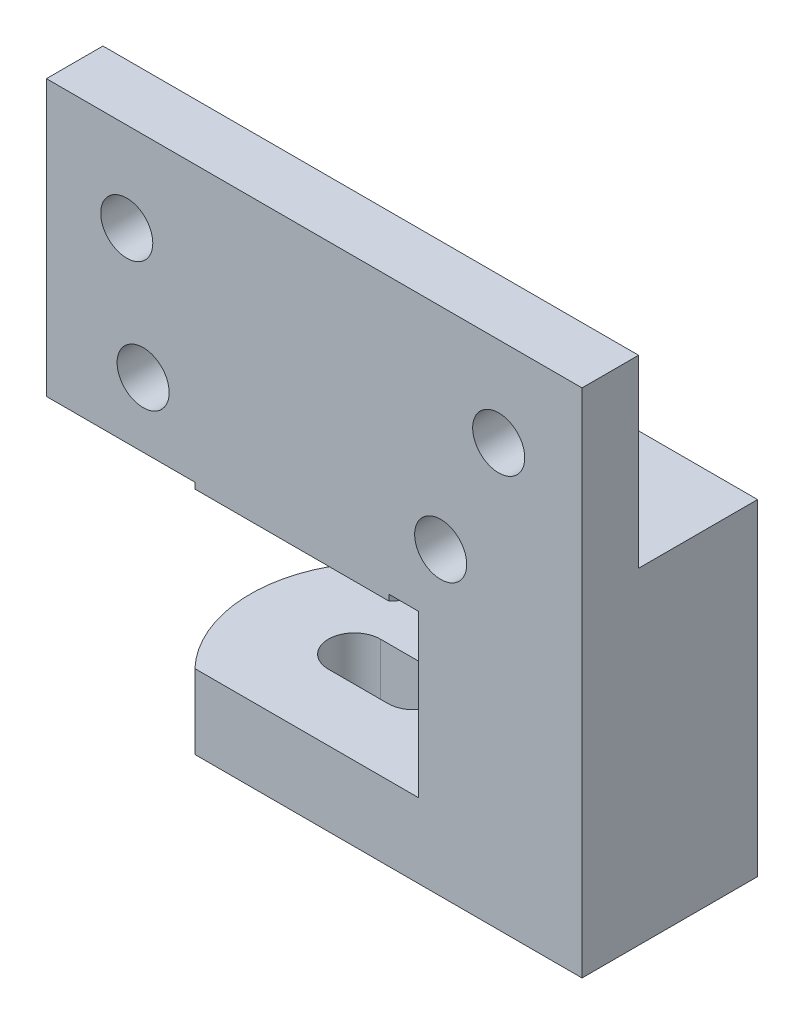
from build123d import *

# Parameters (mm, degrees)
SALIENTE_EXTRUIR2_START    = 0.2
CROQUIS2_W                 = 33
CROQUIS2_H                 = 6.1
SALIENTE_EXTRUIR2_DEPTH    = 11.8
SALIENTE_EXTRUIR3_DEPTH    = 18.5
SALIENTE_EXTRUIR5_DEPTH    = 0.4
SALIENTE_EXTRUIR6_DEPTH    = 3
CORTAR_EXTRUIR1_REACH      = 13.8
CROQUIS5_R                 = 1.75
CORTAR_EXTRUIR2_START      = -6.1
CORTAR_EXTRUIR2_DEPTH      = 2.6
CORTAR_EXTRUIR2_DEPTH_BACK = 3.5
CORTAR_EXTRUIR3_DEPTH      = 1.4
CORTAR_EXTRUIR3_DEPTH_BACK = 19.5
SALIENTE_EXTRUIR7_DEPTH    = 10.85
SALIENTE_EXTRUIR8_DEPTH    = 5
CORTAR_EXTRUIR4_DEPTH      = 35.35


with BuildPart() as part:
    # Croquis2 → Saliente-Extruir2 (new body)
    with BuildSketch(Plane.XY.offset(SALIENTE_EXTRUIR2_START)):
        with Locations((-36.15, -24.15)):
            Rectangle(CROQUIS2_W, CROQUIS2_H)
    extrude(amount=SALIENTE_EXTRUIR2_DEPTH)

    # Croquis3 → Saliente-Extruir3 (add)
    with BuildSketch(Plane.XZ.offset(27.2)):
        with BuildLine():
            Line((-42.671948935, 12), (-52.65, 12))
            Line((-52.65, 12), (-52.65, 8.2))
            Line((-52.65, 8.2), (-44.823559642, 8.2))
            ThreePointArc((-44.823559642, 8.2), (-43.981722047, 10.232475667), (-42.671948935, 12))
        make_face()
        with BuildLine():
            Line((-19.65, 12), (-29.628051065, 12))
            ThreePointArc((-29.628051065, 12), (-28.318277953, 10.232475667), (-27.476440358, 8.2))
            Line((-27.476440358, 8.2), (-19.65, 8.2))
            Line((-19.65, 8.2), (-19.65, 12))
        make_face()
        with BuildLine():
            Line((-29.628051065, 12), (-42.671948935, 12))
            ThreePointArc((-42.671948935, 12), (-43.981722047, 10.232475667), (-44.823559642, 8.2))
            Line((-44.823559642, 8.2), (-27.476440358, 8.2))
            ThreePointArc((-27.476440358, 8.2), (-28.318277953, 10.232475667), (-29.628051065, 12))
        make_face()
    extrude(amount=-SALIENTE_EXTRUIR3_DEPTH)

    # Croquis4 → Saliente-Extruir5 (add)
    with BuildSketch(Plane.XZ.offset(27.2)):
        with BuildLine():
            ThreePointArc((-27.15, 5.798050138), (-27.79244233, 9.137395851), (-29.628051065, 12))
            Line((-29.628051065, 12), (-42.671948935, 12))
            ThreePointArc((-42.671948935, 12), (-45.141099841, 6.198204681), (-43.197115342, 0.2))
            Line((-43.197115342, 0.2), (-29.102884658, 0.2))
            ThreePointArc((-29.102884658, 0.2), (-27.652234468, 2.833597245), (-27.15, 5.798050138))
        make_face()
    extrude(amount=SALIENTE_EXTRUIR5_DEPTH)

    # Croquis6 → Saliente-Extruir6 (add)
    with BuildSketch(Plane(origin=(-19.65, 0, 0), x_dir=(0, 0, -1), z_dir=(1, 0, 0))):
        Polygon((-0.2, -21.1), (-8.2, -21.1), (-8.2, -8.7), (-12, -8.7), (-12, -27.2), (-0.2, -27.2), align=None)
    extrude(amount=SALIENTE_EXTRUIR6_DEPTH)

    # Croquis5 → Cortar-Extruir1 (cut, up to next)
    with BuildSketch(Plane.XY.offset(12), mode=Mode.PRIVATE) as cortar_extruir1_sk1:
        with Locations((-22.25, -14.7)):
            Circle(CROQUIS5_R)
    cortar_extruir1_tool1 = extrude(cortar_extruir1_sk1.sketch, amount=-CORTAR_EXTRUIR1_REACH, mode=Mode.PRIVATE) & part.part
    add(cortar_extruir1_tool1.solids().sort_by_distance((-22.25, -14.7, 12))[0], mode=Mode.SUBTRACT)
    # Croquis5 → Cortar-Extruir1 (cut, up to next)
    with BuildSketch(Plane.XY.offset(12), mode=Mode.PRIVATE) as cortar_extruir1_sk2:
        with Locations((-47.25, -14.7)):
            Circle(CROQUIS5_R)
    cortar_extruir1_tool2 = extrude(cortar_extruir1_sk2.sketch, amount=-CORTAR_EXTRUIR1_REACH, mode=Mode.PRIVATE) & part.part
    add(cortar_extruir1_tool2.solids().sort_by_distance((-47.25, -14.7, 12))[0], mode=Mode.SUBTRACT)
    # Croquis5 → Cortar-Extruir1 (cut, up to next)
    with BuildSketch(Plane.XY.offset(12), mode=Mode.PRIVATE) as cortar_extruir1_sk3:
        with Locations((-46.15, -22.849986467)):
            Circle(CROQUIS5_R)
    cortar_extruir1_tool3 = extrude(cortar_extruir1_sk3.sketch, amount=-CORTAR_EXTRUIR1_REACH, mode=Mode.PRIVATE) & part.part
    add(cortar_extruir1_tool3.solids().sort_by_distance((-46.15, -22.849986, 12))[0], mode=Mode.SUBTRACT)
    # Croquis5 → Cortar-Extruir1 (cut, up to next)
    with BuildSketch(Plane.XY.offset(12), mode=Mode.PRIVATE) as cortar_extruir1_sk4:
        with Locations((-26.15, -22.849986467)):
            Circle(CROQUIS5_R)
    cortar_extruir1_tool4 = extrude(cortar_extruir1_sk4.sketch, amount=-CORTAR_EXTRUIR1_REACH, mode=Mode.PRIVATE) & part.part
    add(cortar_extruir1_tool4.solids().sort_by_distance((-26.15, -22.849986, 12))[0], mode=Mode.SUBTRACT)

    # Croquis7 → Cortar-Extruir2 (cut, two sides)
    with BuildSketch(Plane.XZ.offset(27.2).offset(CORTAR_EXTRUIR2_START)) as cortar_extruir2_sk:
        Polygon((-41.612050808, 5.798050138), (-39.88, 2.798050138), (-32.42, 2.798050138), (-30.687949192, 5.798050138), (-32.42, 8.798050138), (-39.88, 8.798050138), align=None)
    extrude(amount=CORTAR_EXTRUIR2_DEPTH, mode=Mode.SUBTRACT)
    extrude(cortar_extruir2_sk.sketch, amount=-CORTAR_EXTRUIR2_DEPTH_BACK, mode=Mode.SUBTRACT)

    # Croquis7_3 → Cortar-Extruir3 (cut, two sides)
    with BuildSketch(Plane.XZ.offset(27.2)) as cortar_extruir3_sk:
        with BuildLine():
            ThreePointArc((-37.85, 5.798050138), (-36.15, 4.098050138), (-34.45, 5.798050138))
            Line((-34.45, 5.798050138), (-37.85, 5.798050138))
        make_face()
        with BuildLine():
            Line((-37.85, 5.798050138), (-34.45, 5.798050138))
            ThreePointArc((-34.45, 5.798050138), (-36.15, 7.498050138), (-37.85, 5.798050138))
        make_face()
    extrude(amount=CORTAR_EXTRUIR3_DEPTH, mode=Mode.SUBTRACT)
    extrude(cortar_extruir3_sk.sketch, amount=-CORTAR_EXTRUIR3_DEPTH_BACK, mode=Mode.SUBTRACT)

    # Croquis8 → Saliente-Extruir7 (add)
    with BuildSketch(Plane.XZ.offset(27.2)):
        with BuildLine():
            Line((-27.219735144, 0.2), (-16.65, 0.2))
            Line((-16.65, 0.2), (-16.65, 12))
            Line((-16.65, 12), (-27.628051065, 12))
            ThreePointArc((-27.628051065, 12), (-25.616484844, 6.162541828), (-27.219735144, 0.2))
        make_face()
    extrude(amount=SALIENTE_EXTRUIR7_DEPTH)

    # Croquis9 → Saliente-Extruir8 (add)
    with BuildSketch(Plane.XZ.offset(38.05)):
        with BuildLine():
            Line((-16.65, 12), (-16.65, 0.2))
            Line((-16.65, 0.2), (-43.197115342, 0.2))
            ThreePointArc((-43.197115342, 0.2), (-45.141099841, 6.198204681), (-42.671948935, 12))
            Line((-42.671948935, 12), (-16.65, 12))
        make_face()
    extrude(amount=SALIENTE_EXTRUIR8_DEPTH)

    # Croquis10 → Cortar-Extruir4 (cut, through all)
    with BuildSketch(Plane.XZ.offset(43.05)):
        with BuildLine():
            Line((-38.15, 7.548050138), (-34.15, 7.548050138))
            ThreePointArc((-34.15, 7.548050138), (-32.4, 5.798050138), (-34.15, 4.048050138))
            Line((-34.15, 4.048050138), (-38.15, 4.048050138))
            ThreePointArc((-38.15, 4.048050138), (-39.9, 5.798050138), (-38.15, 7.548050138))
        make_face()
    extrude(amount=-CORTAR_EXTRUIR4_DEPTH, mode=Mode.SUBTRACT)


solid = part.part
